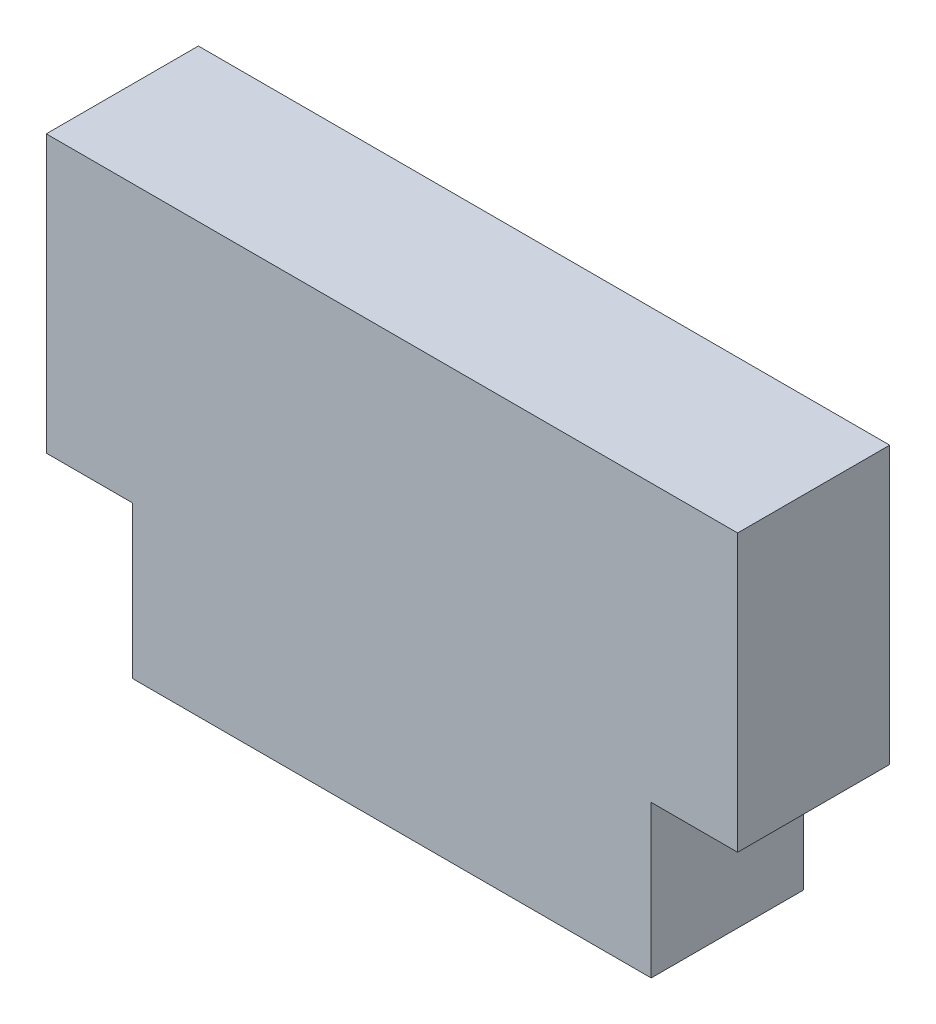
from build123d import *

# Parameters (mm, degrees)
BOSS_EXTRUDE1_DEPTH = 5.588


with BuildPart() as part:
    # Sketch1 → Boss-Extrude1 (new body)
    with BuildSketch(Plane.XY):
        Polygon((-12.7, -5.08), (-9.525, -5.08), (-9.525, -10.668), (9.525, -10.668), (9.525, -5.08), (12.7, -5.08), (12.7, 5.08), (-12.7, 5.08), align=None)
    extrude(amount=BOSS_EXTRUDE1_DEPTH)


solid = part.part
